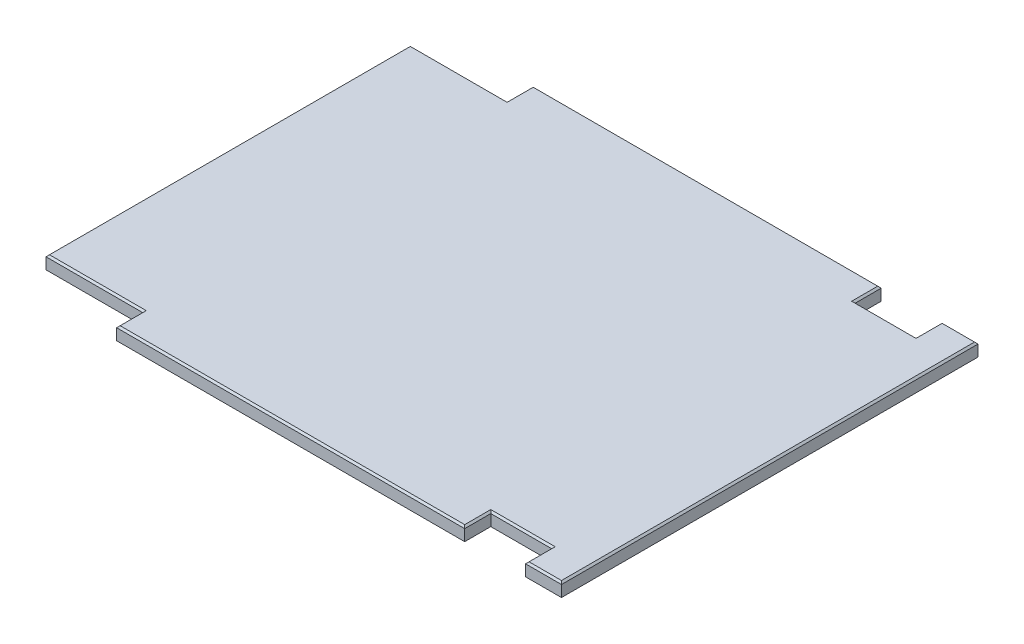
from build123d import *

# Parameters (mm, degrees)
SKETCH1_W           = 790.575
SKETCH1_H           = 608.0125
BOSS_EXTRUDE1_DEPTH = 19.05
SKETCH2_W           = 88.9
SKETCH2_H           = 38.1
SKETCH2_W_2         = 141.2875
CUT_EXTRUDE1_DEPTH  = 20.05
CHAMFER1_SIZE       = 2.54


with BuildPart() as part:
    # Sketch1 → Boss-Extrude1 (new body)
    with BuildSketch(Plane(origin=(0, 0, 0), x_dir=(1, 0, 0), z_dir=(0, 1, 0))):
        with Locations((395.2875, 304.00625)):
            Rectangle(SKETCH1_W, SKETCH1_H)
    extrude(amount=BOSS_EXTRUDE1_DEPTH)

    # Sketch2 → Cut-Extrude1 (cut, through all)
    with BuildSketch(Plane(origin=(0, 19.05, 0), x_dir=(1, 0, 0), z_dir=(0, 1, 0))):
        with Locations((693.7375, 588.9625)):
            Rectangle(SKETCH2_W, SKETCH2_H)
        with Locations((70.64375, 588.9625)):
            Rectangle(SKETCH2_W_2, SKETCH2_H)
        with Locations((70.64375, 19.05)):
            Rectangle(SKETCH2_W_2, SKETCH2_H)
        with Locations((693.7375, 19.05)):
            Rectangle(SKETCH2_W, SKETCH2_H)
    extrude(amount=-CUT_EXTRUDE1_DEPTH, mode=Mode.SUBTRACT)

    # Chamfer1
    chamfer1_edges = [part.edges().sort_by_distance(p)[0] for p in [
        (790.575, 19.05, -304.00625),
        (764.38125, 19.05, -608.0125),
        (0, 19.05, -304.00625),
        (395.2875, 19.05, 0),
        (764.38125, 19.05, 0),
        (395.2875, 19.05, -608.0125),
        (693.7375, 19.05, -38.1),
        (649.2875, 19.05, -19.05),
        (738.1875, 19.05, -19.05),
        (141.2875, 19.05, -19.05),
        (70.64375, 19.05, -38.1),
        (70.64375, 19.05, -569.9125),
        (141.2875, 19.05, -588.9625),
        (738.1875, 19.05, -588.9625),
        (649.2875, 19.05, -588.9625),
        (693.7375, 19.05, -569.9125),
    ]]
    chamfer(chamfer1_edges, length=CHAMFER1_SIZE)


solid = part.part
